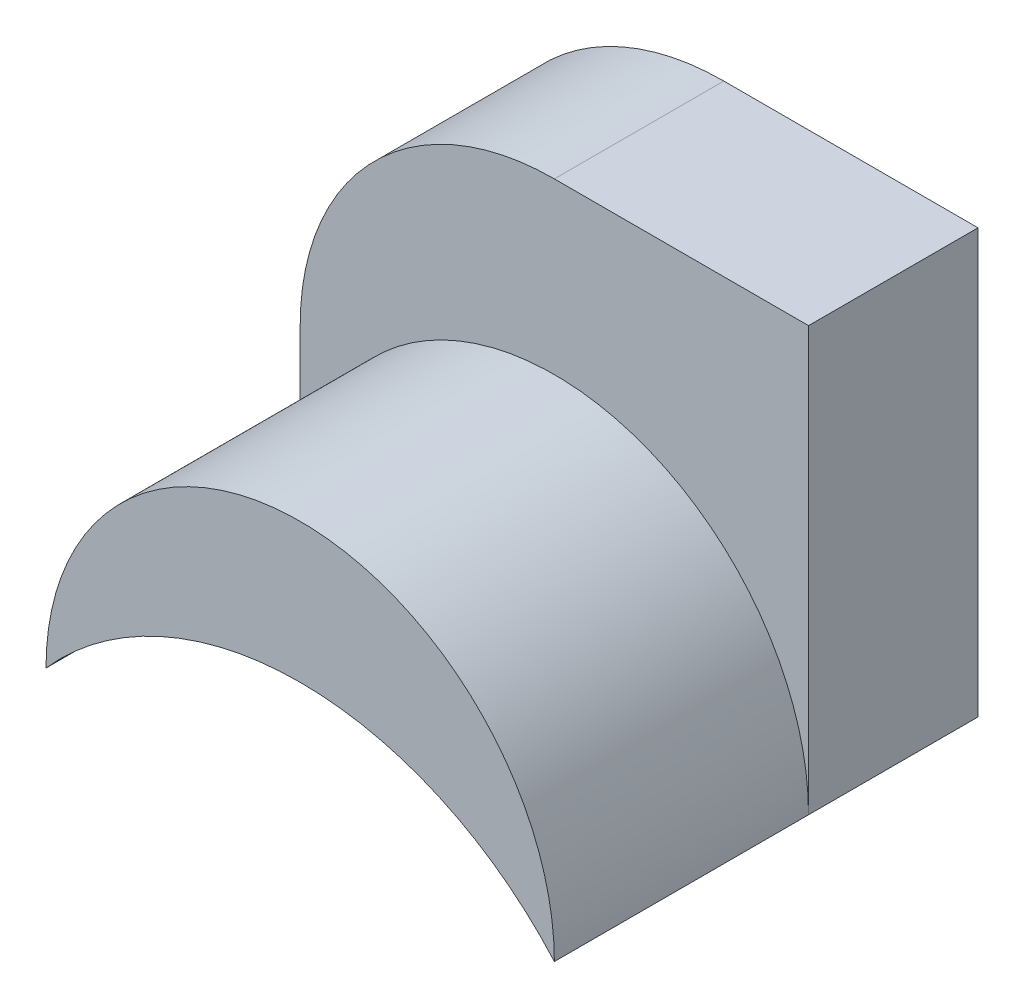
from build123d import *

# Parameters (mm, degrees)
BOSS_EXTRUDE1_DEPTH = 10
BOSS_EXTRUDE2_DEPTH = 15


with BuildPart() as part:
    # Sketch1 → Boss-Extrude1 (new body)
    with BuildSketch(Plane.XY):
        with BuildLine():
            Line((-15, 25), (0, 25))
            Line((0, 25), (0, 0))
            Line((0, 0), (-30, 0))
            Line((-30, 0), (-30, 10))
            ThreePointArc((-30, 10), (-25.606601718, 20.606601718), (-15, 25))
        make_face()
    extrude(amount=BOSS_EXTRUDE1_DEPTH)

    # Sketch2 → Boss-Extrude2 (add)
    with BuildSketch(Plane.XY.offset(10)):
        with BuildLine():
            ThreePointArc((-30, 0), (-15, 15), (0, 0))
            ThreePointArc((0, 0), (-15, 6.771243445), (-30, 0))
        make_face()
    extrude(amount=BOSS_EXTRUDE2_DEPTH)


solid = part.part
